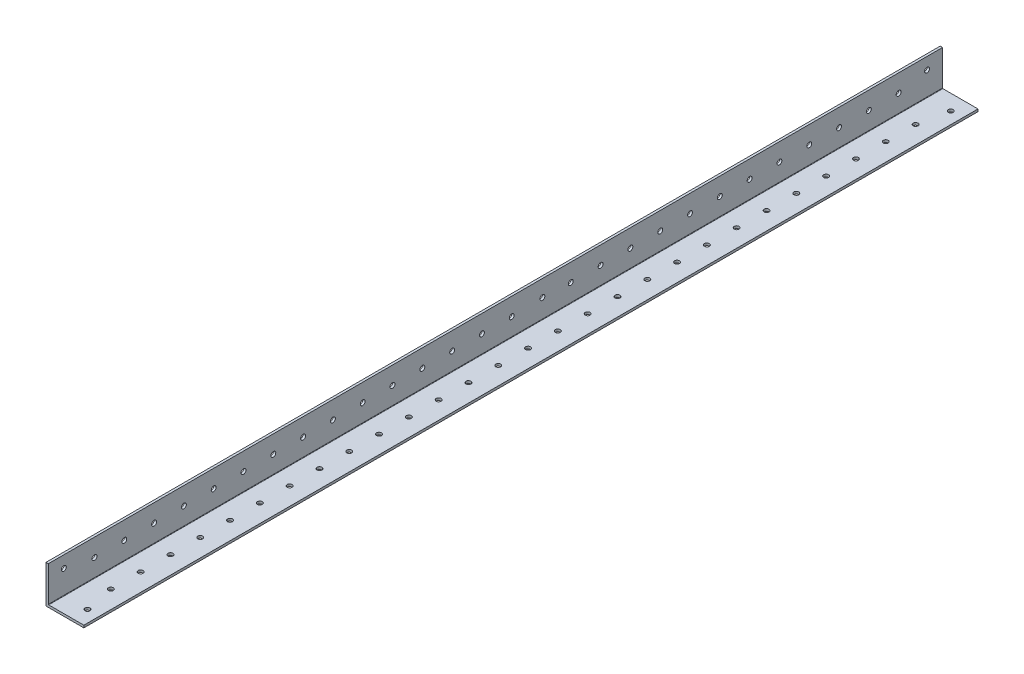
from build123d import *

# Parameters (mm, degrees)
BOSS_EXTRUDE1_DEPTH = 1219.2
FILLET1_R           = 0.254
SKETCH4_W           = 1838.4
SKETCH4_H           = 74.945320812
CUT_EXTRUDE1_DEPTH  = 60
SKETCH5_R           = 1.65
CUT_EXTRUDE2_DEPTH  = 10
SKETCH9_R           = 1.65
CUT_EXTRUDE6_DEPTH  = 60


with BuildPart() as part:
    # Sketch3 → Boss-Extrude1 (new, symmetric)
    with BuildSketch(Plane.XY):
        Polygon((1.5875, 25.4), (0, 25.4), (0, 0), (25.4, 0), (25.4, 1.5875), (1.5875, 1.5875), align=None)
    extrude(amount=BOSS_EXTRUDE1_DEPTH, both=True)

    # Fillet1
    fillet1_edges = [part.edges().sort_by_distance(p)[0] for p in [
        (1.5875, 1.5875, 0),
    ]]
    fillet(fillet1_edges, radius=FILLET1_R)

    # Sketch4 → Cut-Extrude1 (cut)
    with BuildSketch(Plane.ZY):
        with Locations((-300, 37.472660406)):
            Rectangle(SKETCH4_W, SKETCH4_H)
    extrude(amount=-CUT_EXTRUDE1_DEPTH, mode=Mode.SUBTRACT)

    # Sketch5 → Cut-Extrude2 (cut)
    with BuildSketch(Plane(origin=(0, 1.5875, 0), x_dir=(1, 0, 0), z_dir=(0, 1, 0))):
        with Locations(Location((17.4625, -629.5759, 0), (0, 0, 180))):
            Circle(SKETCH5_R)
        with Locations(Location((17.4625, -1208.8241, 0), (0, 0, 180))):
            Circle(SKETCH5_R)
        with Locations(Location((13.49375, -1189.2, 0), (0, 0, 180))):
            Circle(SKETCH5_R)
        with Locations(Location((13.49375, -1169.2, 0), (0, 0, 180))):
            Circle(SKETCH5_R)
        with Locations(Location((13.49375, -1149.2, 0), (0, 0, 180))):
            Circle(SKETCH5_R)
        with Locations(Location((13.49375, -1129.2, 0), (0, 0, 180))):
            Circle(SKETCH5_R)
        with Locations(Location((13.49375, -1109.2, 0), (0, 0, 180))):
            Circle(SKETCH5_R)
        with Locations(Location((13.49375, -1089.2, 0), (0, 0, 180))):
            Circle(SKETCH5_R)
        with Locations(Location((13.49375, -1069.2, 0), (0, 0, 180))):
            Circle(SKETCH5_R)
        with Locations(Location((13.49375, -1049.2, 0), (0, 0, 180))):
            Circle(SKETCH5_R)
        with Locations(Location((13.49375, -1029.2, 0), (0, 0, 180))):
            Circle(SKETCH5_R)
        with Locations(Location((13.49375, -1009.2, 0), (0, 0, 180))):
            Circle(SKETCH5_R)
        with Locations(Location((13.49375, -989.2, 0), (0, 0, 180))):
            Circle(SKETCH5_R)
        with Locations(Location((13.49375, -969.2, 0), (0, 0, 180))):
            Circle(SKETCH5_R)
        with Locations(Location((13.49375, -949.2, 0), (0, 0, 180))):
            Circle(SKETCH5_R)
        with Locations(Location((13.49375, -929.2, 0), (0, 0, 180))):
            Circle(SKETCH5_R)
        with Locations(Location((13.49375, -909.2, 0), (0, 0, 180))):
            Circle(SKETCH5_R)
        with Locations(Location((13.49375, -889.2, 0), (0, 0, 180))):
            Circle(SKETCH5_R)
        with Locations(Location((13.49375, -869.2, 0), (0, 0, 180))):
            Circle(SKETCH5_R)
        with Locations(Location((13.49375, -849.2, 0), (0, 0, 180))):
            Circle(SKETCH5_R)
        with Locations(Location((13.49375, -829.2, 0), (0, 0, 180))):
            Circle(SKETCH5_R)
        with Locations(Location((13.49375, -809.2, 0), (0, 0, 180))):
            Circle(SKETCH5_R)
        with Locations(Location((13.49375, -789.2, 0), (0, 0, 180))):
            Circle(SKETCH5_R)
        with Locations(Location((13.49375, -769.2, 0), (0, 0, 180))):
            Circle(SKETCH5_R)
        with Locations(Location((13.49375, -749.2, 0), (0, 0, 180))):
            Circle(SKETCH5_R)
        with Locations(Location((13.49375, -729.2, 0), (0, 0, 180))):
            Circle(SKETCH5_R)
        with Locations(Location((13.49375, -709.2, 0), (0, 0, 180))):
            Circle(SKETCH5_R)
        with Locations(Location((13.49375, -689.2, 0), (0, 0, 180))):
            Circle(SKETCH5_R)
        with Locations(Location((13.49375, -669.2, 0), (0, 0, 180))):
            Circle(SKETCH5_R)
        with Locations(Location((13.49375, -649.2, 0), (0, 0, 180))):
            Circle(SKETCH5_R)
    extrude(amount=-CUT_EXTRUDE2_DEPTH, mode=Mode.SUBTRACT)

    # Sketch9 → Cut-Extrude6 (cut)
    with BuildSketch(Plane(origin=(1.5875, 0, 0), x_dir=(0, 0, -1), z_dir=(1, 0, 0))):
        with Locations((-629.5759, 17.4625)):
            Circle(SKETCH9_R)
        with Locations((-648.634825, 13.49375)):
            Circle(SKETCH9_R)
        with Locations((-887.69375, 14.2875)):
            Circle(SKETCH9_R)
        with Locations((-1208.8241, 17.4625)):
            Circle(SKETCH9_R)
        with Locations((-668.634825, 13.49375)):
            Circle(SKETCH9_R)
        with Locations((-688.634825, 13.49375)):
            Circle(SKETCH9_R)
        with Locations((-708.634825, 13.49375)):
            Circle(SKETCH9_R)
        with Locations((-728.634825, 13.49375)):
            Circle(SKETCH9_R)
        with Locations((-748.634825, 13.49375)):
            Circle(SKETCH9_R)
        with Locations((-768.634825, 13.49375)):
            Circle(SKETCH9_R)
        with Locations((-788.634825, 13.49375)):
            Circle(SKETCH9_R)
        with Locations((-808.634825, 13.49375)):
            Circle(SKETCH9_R)
        with Locations((-828.634825, 13.49375)):
            Circle(SKETCH9_R)
        with Locations((-848.634825, 13.49375)):
            Circle(SKETCH9_R)
        with Locations((-868.634825, 13.49375)):
            Circle(SKETCH9_R)
        with Locations((-908.258925, 13.49375)):
            Circle(SKETCH9_R)
        with Locations((-928.258925, 13.49375)):
            Circle(SKETCH9_R)
        with Locations((-948.258925, 13.49375)):
            Circle(SKETCH9_R)
        with Locations((-968.258925, 13.49375)):
            Circle(SKETCH9_R)
        with Locations((-988.258925, 13.49375)):
            Circle(SKETCH9_R)
        with Locations((-1008.258925, 13.49375)):
            Circle(SKETCH9_R)
        with Locations((-1028.258925, 13.49375)):
            Circle(SKETCH9_R)
        with Locations((-1048.258925, 13.49375)):
            Circle(SKETCH9_R)
        with Locations((-1068.258925, 13.49375)):
            Circle(SKETCH9_R)
        with Locations((-1088.258925, 13.49375)):
            Circle(SKETCH9_R)
        with Locations((-1108.258925, 13.49375)):
            Circle(SKETCH9_R)
        with Locations((-1128.258925, 13.49375)):
            Circle(SKETCH9_R)
        with Locations((-1148.258925, 13.49375)):
            Circle(SKETCH9_R)
        with Locations((-1168.258925, 13.49375)):
            Circle(SKETCH9_R)
        with Locations((-1188.258925, 13.49375)):
            Circle(SKETCH9_R)
    extrude(amount=-CUT_EXTRUDE6_DEPTH, mode=Mode.SUBTRACT)


solid = part.part
